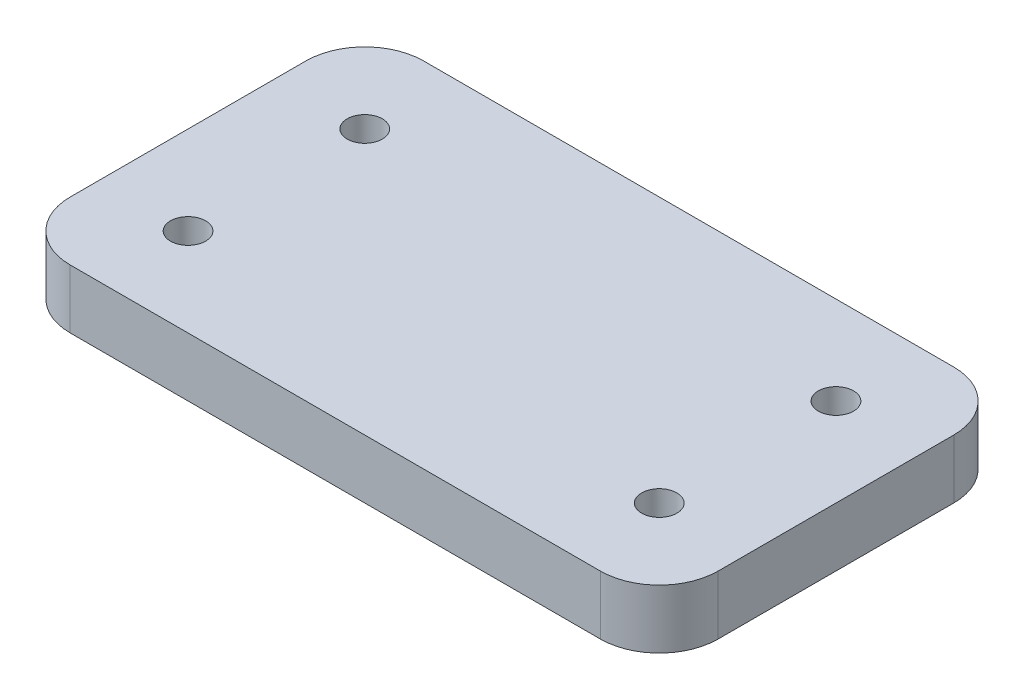
from build123d import *

# Parameters (mm, degrees)
SKETCH1_W                 = 69.85
SKETCH1_H                 = 38.1
BOSS_EXTRUDE1_DEPTH       = 6.35
F_6_CLEARANCE_HOLE1_D     = 3.7973
F_6_CLEARANCE_HOLE1_DEPTH = 25.4
F_6_CLEARANCE_HOLE1_TIP   = 1.140824014
FILLET1_R                 = 6.35


with BuildPart() as part:
    # Sketch1 → Boss-Extrude1 (new body)
    with BuildSketch(Plane(origin=(0, 0, 0), x_dir=(1, 0, 0), z_dir=(0, 1, 0))):
        Rectangle(SKETCH1_W, SKETCH1_H)
    extrude(amount=BOSS_EXTRUDE1_DEPTH)

    # #6 Clearance Hole1
    with Locations(Plane.XZ):
        with Locations((-25.4, 9.525), (25.4, -9.525), (-25.4, -9.525), (25.4, 9.525)):
            Hole(F_6_CLEARANCE_HOLE1_D / 2, depth=F_6_CLEARANCE_HOLE1_DEPTH)
            with Locations((0, 0, -(F_6_CLEARANCE_HOLE1_DEPTH + F_6_CLEARANCE_HOLE1_TIP / 2))):  # 118° drill point
                Cone(0, F_6_CLEARANCE_HOLE1_D / 2, F_6_CLEARANCE_HOLE1_TIP, mode=Mode.SUBTRACT)

    # Fillet1
    fillet1_edges = [part.edges().sort_by_distance(p)[0] for p in [
        (-34.925, 3.175, -19.05),
        (34.925, 3.175, -19.05),
        (34.925, 3.175, 19.05),
        (-34.925, 3.175, 19.05),
    ]]
    fillet(fillet1_edges, radius=FILLET1_R)


solid = part.part
